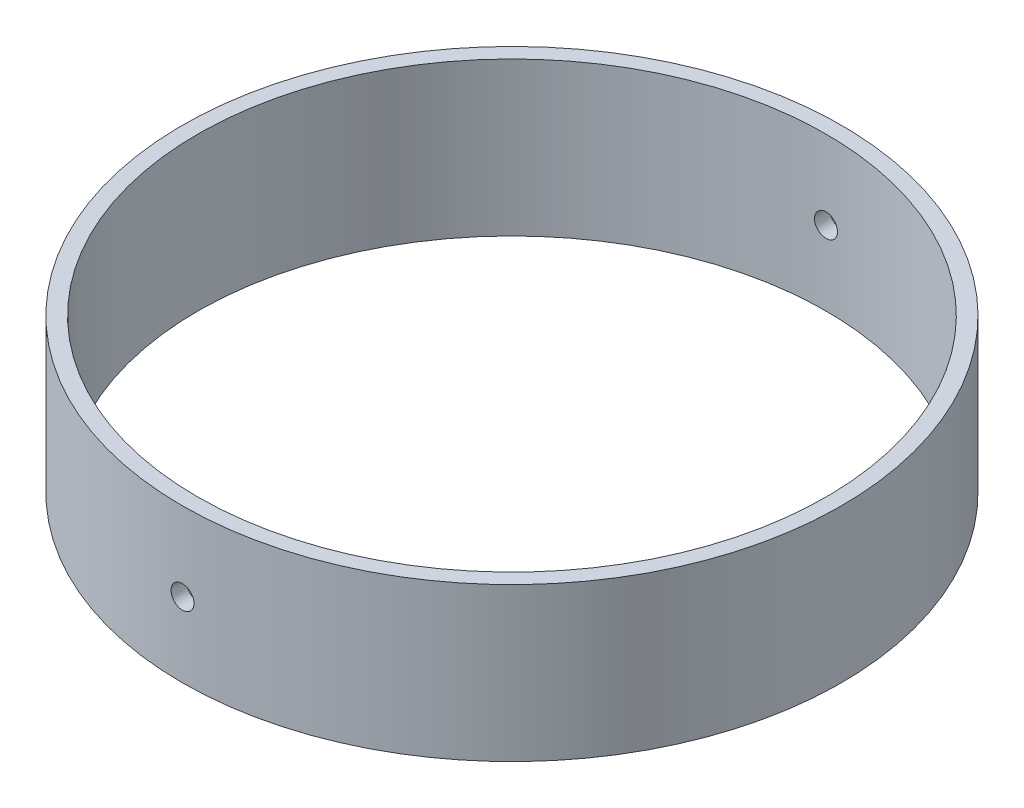
from build123d import *

# Parameters (mm, degrees)
SKETCH1_R           = 54.61
SKETCH1_R_2         = 52.07
BOSS_EXTRUDE1_DEPTH = 25.4
SKETCH3_R           = 1.905
CUT_EXTRUDE1_DEPTH  = 82.299841328
CIRPATTERN1_COUNT   = 2


with BuildPart() as part:
    # Sketch1 → Boss-Extrude1 (new body)
    with BuildSketch(Plane(origin=(0, 0, 0), x_dir=(1, 0, 0), z_dir=(0, 1, 0))):
        with Locations(Location((0, 0, 0), (0, 0, 270))):
            Circle(SKETCH1_R)
        with Locations(Location((0, 0, 0), (0, 0, 270))):
            Circle(SKETCH1_R_2, mode=Mode.SUBTRACT)
    extrude(amount=BOSS_EXTRUDE1_DEPTH)

    # Sketch3 → Cut-Extrude1 (cut, through all)
    with BuildSketch(Plane.XY):
        with Locations(Location((0, 12.328955527, 0), (0, 0, 90.000000049))):
            Circle(SKETCH3_R)
    cut_extrude1 = extrude(amount=CUT_EXTRUDE1_DEPTH, mode=Mode.SUBTRACT)

    # CirPattern1: Cut-Extrude1 ×2 about axis
    cirpattern1_axis = Axis((0, 25.4, 0), (0, 1, 0))
    for i in range(1, CIRPATTERN1_COUNT):
        add(cut_extrude1.rotate(cirpattern1_axis, i * 360 / CIRPATTERN1_COUNT), mode=Mode.SUBTRACT)


solid = part.part
